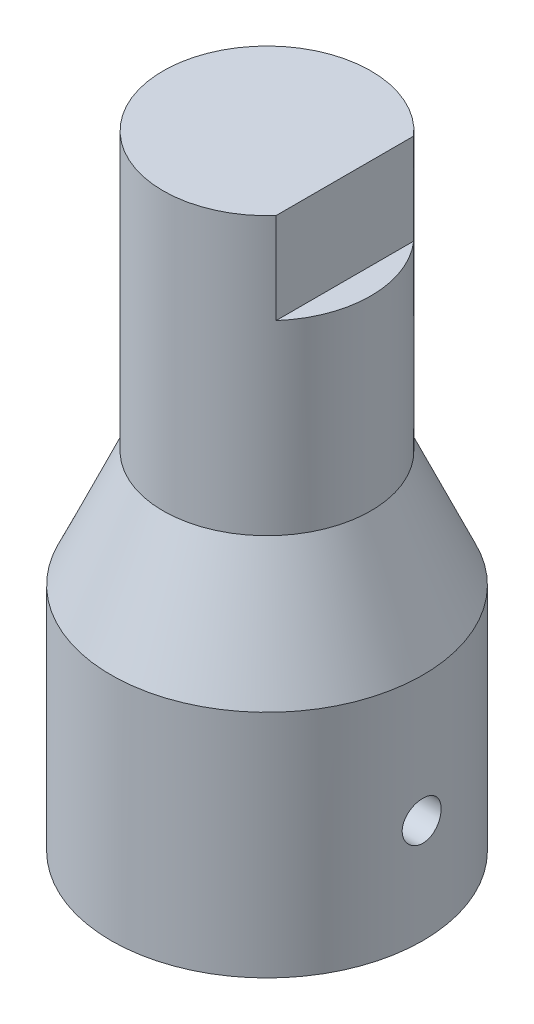
from build123d import *

# Parameters (mm, degrees)
SKETCH1_R           = 9.525
BOSS_EXTRUDE1_DEPTH = 14.06
SKETCH2_R           = 6.35
BOSS_EXTRUDE2_DEPTH = 16.94
SKETCH3_W           = 1.59
SKETCH3_H           = 5.56
CUT_EXTRUDE1_DEPTH  = 8.47
SKETCH5_R           = 1.19
CUT_EXTRUDE3_DEPTH  = 14.06
SKETCH4_R           = 5.555
CUT_EXTRUDE4_DEPTH  = 14.06


with BuildPart() as part:
    # Sketch1 → Boss-Extrude1 (new body)
    with BuildSketch(Plane(origin=(0, 0, 0), x_dir=(1, 0, 0), z_dir=(0, 1, 0))):
        with Locations(Location((0, 0, 0), (0, 0, 270))):
            Circle(SKETCH1_R)
    extrude(amount=BOSS_EXTRUDE1_DEPTH)



with BuildPart() as body_2:
    # Sketch2 → Boss-Extrude2 (new body)
    with BuildSketch(Plane(origin=(0, 38.1, 0), x_dir=(1, 0, 0), z_dir=(0, 1, 0))):
        with Locations(Location((0, 0, 0), (0, 0, 270))):
            Circle(SKETCH2_R)
    extrude(amount=-BOSS_EXTRUDE2_DEPTH)


with BuildPart() as part_1:
    add(part.part)

    add(body_2.part)  # loft1 joins it to this body
    # loft up to a face of the part (loft1)
    loft([Face(Wire([part_1.edges().sort_by_distance((6.943426176, 14.06, -6.520311184))[0]])), Face(Wire([part_1.edges().sort_by_distance((-4.628950784, 21.16, -4.346874123))[0]]))])

    # Sketch3 → Cut-Extrude1 (cut, symmetric)
    with BuildSketch(Plane.XY):
        with Locations((5.555, 35.32)):
            Rectangle(SKETCH3_W, SKETCH3_H)
    extrude(amount=CUT_EXTRUDE1_DEPTH, both=True, mode=Mode.SUBTRACT)

    # Sketch5 → Cut-Extrude3 (cut)
    with BuildSketch(Plane(origin=(0, 0, 0), x_dir=(0, 0, -1), z_dir=(1, 0, 0))):
        with Locations(Location((0, 6.35, 0), (0, 0, 180))):
            Circle(SKETCH5_R)
    extrude(amount=CUT_EXTRUDE3_DEPTH, mode=Mode.SUBTRACT)

    # Sketch4 → Cut-Extrude4 (cut)
    with BuildSketch(Plane.XZ):
        with Locations(Location((-0.795, -0.79, 0), (0, 0, 270))):
            Circle(SKETCH4_R)
    extrude(amount=-CUT_EXTRUDE4_DEPTH, mode=Mode.SUBTRACT)


solid = part_1.part
